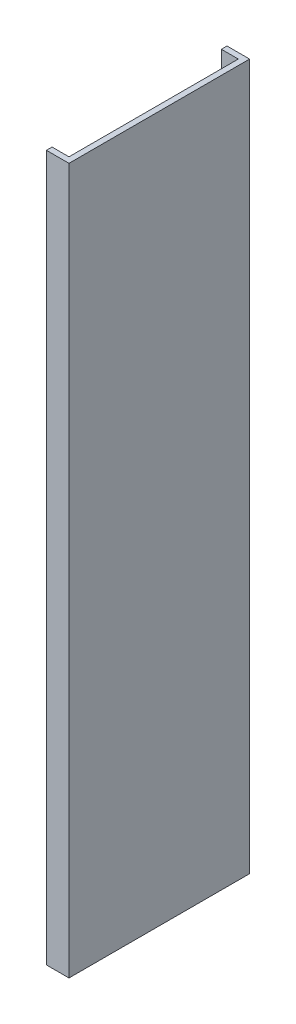
from build123d import *

# Parameters (mm, degrees)
EXTRUDE_THIN1_DEPTH = 625


with BuildPart() as part:
    # Sketch1 → Extrude-Thin1 (new body)
    with BuildSketch(Plane(origin=(0, 0, 0), x_dir=(1, 0, 0), z_dir=(0, 1, 0))):
        Polygon((-15, 75), (0, 75), (0, -75), (-15, -75), (-15, -80), (5, -80), (5, 80), (-15, 80), align=None)
    extrude(amount=EXTRUDE_THIN1_DEPTH)


solid = part.part
